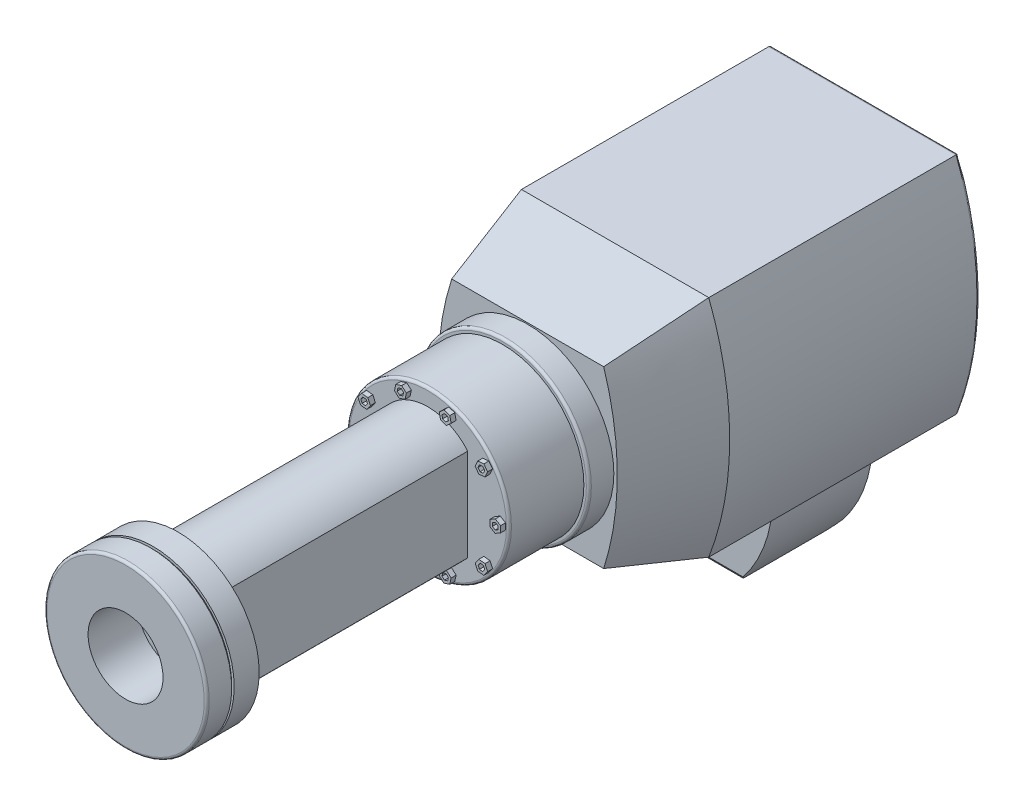
from build123d import *

# Parameters (mm, degrees)
BOSS_EXTRUDE1_DEPTH  = 100
SKETCH7_R            = 34.5
BOSS_EXTRUDE2_DEPTH  = 10
SKETCH8_R            = 32.5
BOSS_EXTRUDE3_DEPTH  = 30
BOSS_EXTRUDE4_DEPTH  = 2
CIRPATTERN1_COUNT    = 10
BOSS_EXTRUDE5_DEPTH  = 100
SKETCH12_R           = 32.5
BOSS_EXTRUDE6_DEPTH  = 10
SKETCH13_R           = 31.5
BOSS_EXTRUDE7_DEPTH  = 1
SKETCH14_R           = 32.5
BOSS_EXTRUDE8_DEPTH  = 10
SKETCH15_R           = 42.5
BOSS_EXTRUDE9_DEPTH  = 10.5
BOSS_EXTRUDE10_DEPTH = 35
BOSS_EXTRUDE11_DEPTH = 20
CUT_EXTRUDE1_DEPTH   = 38.880962203
FILLET1_R            = 1
SKETCH19_R           = 15
CUT_EXTRUDE2_DEPTH   = 20
SKETCH20_R           = 15
CUT_EXTRUDE3_DEPTH   = 20


with BuildPart() as part:
    # Sketch1 → Boss-Extrude1 (new body)
    with BuildSketch(Plane.XY):
        with BuildLine():
            Line((-37.5, 45), (37.5, 45))
            ThreePointArc((37.5, 45), (45.880962103, 0), (37.5, -45))
            Line((37.5, -45), (-37.5, -45))
            ThreePointArc((-37.5, -45), (-45.880962103, 0), (-37.5, 45))
        make_face()
    extrude(amount=BOSS_EXTRUDE1_DEPTH)

    # Sketch4 → Loft2 section 0
    with BuildSketch(Plane.XY.offset(100)):
        with BuildLine():
            Line((37.5, 45), (-37.5, 45))
            ThreePointArc((-37.5, 45), (-45.880962103, 0), (-37.5, -45))
            Line((-37.5, -45), (37.5, -45))
            ThreePointArc((37.5, -45), (45.880962103, 0), (37.5, 45))
        make_face()
    # Sketch6 → Loft2 section 1
    with BuildSketch(Plane.XY.offset(135)):
        with BuildLine():
            Line((30.425473604, 35), (-30.425473604, 35))
            ThreePointArc((-30.425473604, 35), (-35.880962103, 0), (-30.425473604, -35))
            Line((-30.425473604, -35), (30.425473604, -35))
            ThreePointArc((30.425473604, -35), (35.880962103, 0), (30.425473604, 35))
        make_face()
    loft()

    # Sketch7 → Boss-Extrude2 (add)
    with BuildSketch(Plane.XY.offset(135)):
        Circle(SKETCH7_R)
    extrude(amount=BOSS_EXTRUDE2_DEPTH)

    # Sketch8 → Boss-Extrude3 (add)
    with BuildSketch(Plane.XY.offset(145)):
        Circle(SKETCH8_R)
    extrude(amount=BOSS_EXTRUDE3_DEPTH)

    # Sketch9 → Boss-Extrude4 (add)
    with BuildSketch(Plane.XY.offset(175)):
        Polygon((29, 2.5), (26.834936491, 1.25), (26.834936491, -1.25), (29, -2.5), (31.165063509, -1.25), (31.165063509, 1.25), align=None)
        Polygon((30.165063509, 0.672649731), (29, 1.345299462), (27.834936491, 0.672649731), (27.834936491, -0.672649731), (29, -1.345299462), (30.165063509, -0.672649731), align=None, mode=Mode.SUBTRACT)
    boss_extrude4 = extrude(amount=BOSS_EXTRUDE4_DEPTH)

    # CirPattern1: Boss-Extrude4 ×10 about axis
    cirpattern1_axis = Axis((0, 0, 0), (0, 0, 1))
    for i in range(1, CIRPATTERN1_COUNT):
        add(boss_extrude4.rotate(cirpattern1_axis, i * 360 / CIRPATTERN1_COUNT))

    # Sketch10 → Boss-Extrude5 (add)
    with BuildSketch(Plane.XY.offset(175)):
        with BuildLine():
            Line((16, 18.5), (16, -18.5))
            ThreePointArc((16, -18.5), (0, -25.898529491), (-16, -18.5))
            Line((-16, -18.5), (-16, 18.5))
            ThreePointArc((-16, 18.5), (0, 25.898529491), (16, 18.5))
        make_face()
    extrude(amount=BOSS_EXTRUDE5_DEPTH)

    # Sketch12 → Boss-Extrude6 (add)
    with BuildSketch(Plane.XY.offset(275)):
        Circle(SKETCH12_R)
    extrude(amount=BOSS_EXTRUDE6_DEPTH)

    # Sketch13 → Boss-Extrude7 (add)
    with BuildSketch(Plane.XY.offset(285)):
        Circle(SKETCH13_R)
    extrude(amount=BOSS_EXTRUDE7_DEPTH)

    # Sketch14 → Boss-Extrude8 (add)
    with BuildSketch(Plane.XY.offset(286)):
        Circle(SKETCH14_R)
    extrude(amount=BOSS_EXTRUDE8_DEPTH)

    # Sketch15 → Boss-Extrude9 (add, symmetric)
    with BuildSketch(Plane(origin=(-37.5, 0, 0), x_dir=(0, 0, -1), z_dir=(1, 0, 0))):
        with Locations((-50, -45)):
            Circle(SKETCH15_R)
    extrude(amount=BOSS_EXTRUDE9_DEPTH, both=True)

    # Sketch16 → Boss-Extrude10 (add)
    with BuildSketch(Plane(origin=(-27, 0, 0), x_dir=(0, 0, -1), z_dir=(1, 0, 0))):
        with BuildLine():
            Line((-70, -45), (-70, -75))
            ThreePointArc((-70, -75), (-50, -85.128852225), (-30, -75))
            Line((-30, -75), (-30, -45))
            Line((-30, -45), (-70, -45))
        make_face()
    extrude(amount=BOSS_EXTRUDE10_DEPTH)

    # Sketch17 → Boss-Extrude11 (add, symmetric)
    with BuildSketch(Plane.XY.offset(50)):
        with BuildLine():
            Line((8, -45), (8, -87))
            ThreePointArc((8, -87), (25.421855105, -68.929675658), (33, -45))
            Line((33, -45), (8, -45))
        make_face()
    extrude(amount=BOSS_EXTRUDE11_DEPTH, both=True)

    # Sketch18 → Cut-Extrude1 (cut, through all)
    with BuildSketch(Plane.ZY.offset(-8)):
        with BuildLine():
            Line((70, -87), (70, -75))
            ThreePointArc((70, -75), (50, -85.128852225), (30, -75))
            Line((30, -75), (30, -87))
            Line((30, -87), (70, -87))
        make_face()
    extrude(amount=-CUT_EXTRUDE1_DEPTH, mode=Mode.SUBTRACT)

    # Fillet1
    fillet1_edges = [part.edges().sort_by_distance(p)[0] for p in [
        (-34.5, 0, 145),
        (-32.5, 0, 296),
        (-32.5, 0, 175),
        (-48, -45, 92.5),
        (-27, -87.5, 50),
        (0, -45, 0),
        (-45.880962103, 0, 0),
        (0, 45, 0),
        (45.880962103, 0, 0),
    ]]
    fillet(fillet1_edges, radius=FILLET1_R)

    # Sketch19 → Cut-Extrude2 (cut)
    with BuildSketch(Plane.XY.offset(296)):
        Circle(SKETCH19_R)
    extrude(amount=-CUT_EXTRUDE2_DEPTH, mode=Mode.SUBTRACT)

    # Sketch20 → Cut-Extrude3 (cut)
    with BuildSketch(Plane.ZY.offset(48)):
        with Locations((50, -45)):
            Circle(SKETCH20_R)
    extrude(amount=-CUT_EXTRUDE3_DEPTH, mode=Mode.SUBTRACT)


solid = part.part
